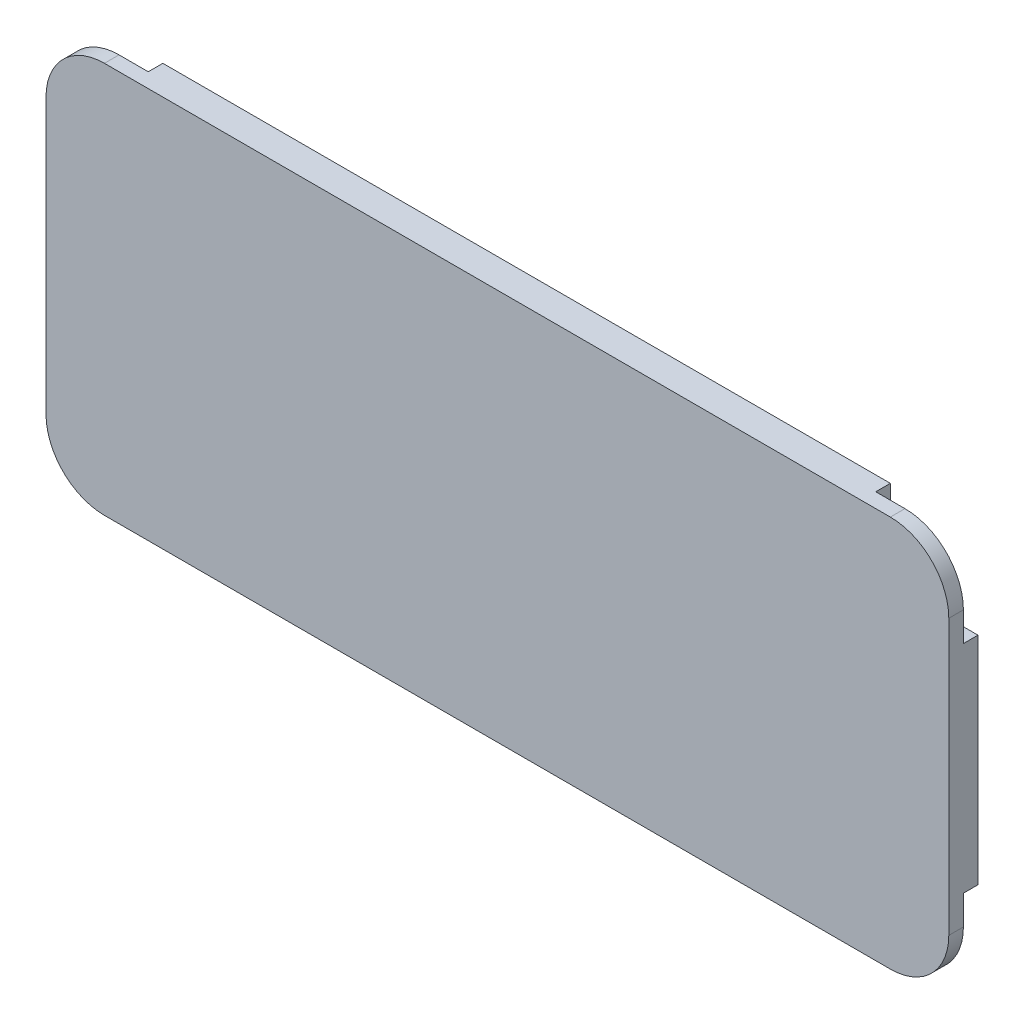
from build123d import *

# Parameters (mm, degrees)
EXTRUDE_1_DEPTH     = 1
CUT_EXTRUDE_2_DEPTH = 0.5


with BuildPart() as part:
    # 草图1 → 凸台-拉伸1 (new body)
    with BuildSketch(Plane.XY):
        with BuildLine():
            Line((2, 0), (28.9, 0))
            ThreePointArc((28.9, 0), (30.314213562, 0.585786438), (30.9, 2))
            Line((30.9, 2), (30.9, 11.4))
            ThreePointArc((30.9, 11.4), (30.314213562, 12.814213562), (28.9, 13.4))
            Line((28.9, 13.4), (2, 13.4))
            ThreePointArc((2, 13.4), (0.585786438, 12.814213562), (0, 11.4))
            Line((0, 11.4), (0, 2))
            ThreePointArc((0, 2), (0.585786438, 0.585786438), (2, 0))
        make_face()
    extrude(amount=EXTRUDE_1_DEPTH)

    # 草图3 → 切除-拉伸2 (cut)
    with BuildSketch(Plane(origin=(0, 0, 0), x_dir=(-1, 0, 0), z_dir=(0, 0, -1))):
        with BuildLine():
            Line((-30.9, 13.4), (-27.9, 13.4))
            Line((-27.9, 13.4), (-27.9, 10.9))
            ThreePointArc((-27.9, 10.9), (-28.046446609, 10.546446609), (-28.4, 10.4))
            Line((-28.4, 10.4), (-30.9, 10.4))
            Line((-30.9, 10.4), (-30.9, 13.4))
        make_face()
        with BuildLine():
            Line((-3, 13.4), (-3, 10.9))
            ThreePointArc((-3, 10.9), (-2.853553391, 10.546446609), (-2.5, 10.4))
            Line((-2.5, 10.4), (0, 10.4))
            Line((0, 10.4), (0, 13.4))
            Line((0, 13.4), (-3, 13.4))
        make_face()
        with BuildLine():
            Line((0, 0), (-3, 0))
            Line((-3, 0), (-3, 2.5))
            ThreePointArc((-3, 2.5), (-2.853553391, 2.853553391), (-2.5, 3))
            Line((-2.5, 3), (0, 3))
            Line((0, 3), (0, 0))
        make_face()
        with BuildLine():
            Line((-27.9, 0), (-27.9, 2.5))
            ThreePointArc((-27.9, 2.5), (-28.046446609, 2.853553391), (-28.4, 3))
            Line((-28.4, 3), (-30.9, 3))
            Line((-30.9, 3), (-30.9, 0))
            Line((-30.9, 0), (-27.9, 0))
        make_face()
    extrude(amount=-CUT_EXTRUDE_2_DEPTH, mode=Mode.SUBTRACT)


solid = part.part
